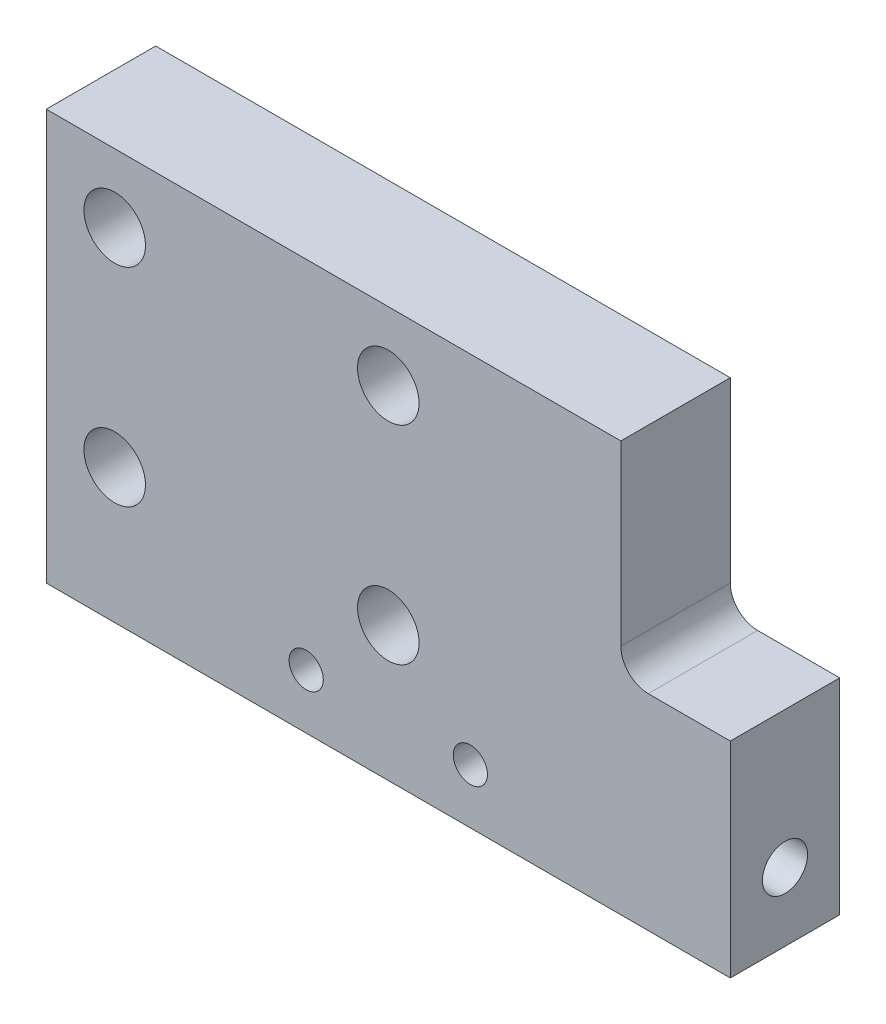
from build123d import *

# Parameters (mm, degrees)
SKETCH2_R             = 2.25
BOSS_EXTRUDE1_DEPTH   = 8
M3_TAPPED_HOLE1_D     = 2.5
M3_TAPPED_HOLE1_DEPTH = 7.5
M3_TAPPED_HOLE1_TIP   = 0.751075774
M4_TAPPED_HOLE1_D     = 3.3
M4_TAPPED_HOLE1_DEPTH = 8
M4_TAPPED_HOLE1_TIP   = 0.991420021
M4_TAPPED_HOLE2_D     = 3.3
M4_TAPPED_HOLE2_DEPTH = 8
M4_TAPPED_HOLE2_TIP   = 0.991420021
FILLET1_R             = 2


with BuildPart() as part:
    # Sketch2 → Boss-Extrude1 (new body)
    with BuildSketch(Plane.XY):
        Polygon((-21.629213483, 13.033707865), (20.370786517, 13.033707865), (20.370786517, -1.966292135), (28.370786517, -1.966292135), (28.370786517, -16.966292135), (-21.629213483, -16.966292135), align=None)
        with Locations((-16.629213483, 8.033707865)):
            Circle(SKETCH2_R, mode=Mode.SUBTRACT)
        with Locations((3.370786517, 8.033707865)):
            Circle(SKETCH2_R, mode=Mode.SUBTRACT)
        with Locations((-16.629213483, -7.134831461)):
            Circle(SKETCH2_R, mode=Mode.SUBTRACT)
        with Locations((3.370786517, -7.134831461)):
            Circle(SKETCH2_R, mode=Mode.SUBTRACT)
    extrude(amount=BOSS_EXTRUDE1_DEPTH)

    # M3 Tapped Hole1
    with Locations(Plane.XY.offset(8)):
        with Locations((-2.629213483, -12.966292135), (9.370786517, -12.966292135)):
            Hole(M3_TAPPED_HOLE1_D / 2, depth=M3_TAPPED_HOLE1_DEPTH)
            with Locations((0, 0, -(M3_TAPPED_HOLE1_DEPTH + M3_TAPPED_HOLE1_TIP / 2))):  # 118° drill point
                Cone(0, M3_TAPPED_HOLE1_D / 2, M3_TAPPED_HOLE1_TIP, mode=Mode.SUBTRACT)

    # M4 Tapped Hole1
    with Locations(Plane(origin=(28.370786517, 0, 0), x_dir=(0, 0, -1), z_dir=(1, 0, 0))):
        with Locations((-4, -11.966292135)):
            Hole(M4_TAPPED_HOLE1_D / 2, depth=M4_TAPPED_HOLE1_DEPTH)
            with Locations((0, 0, -(M4_TAPPED_HOLE1_DEPTH + M4_TAPPED_HOLE1_TIP / 2))):  # 118° drill point
                Cone(0, M4_TAPPED_HOLE1_D / 2, M4_TAPPED_HOLE1_TIP, mode=Mode.SUBTRACT)

    # M4 Tapped Hole2
    with Locations(Plane.ZY.offset(21.629213483)):
        with Locations((4, -11.966292135)):
            Hole(M4_TAPPED_HOLE2_D / 2, depth=M4_TAPPED_HOLE2_DEPTH)
            with Locations((0, 0, -(M4_TAPPED_HOLE2_DEPTH + M4_TAPPED_HOLE2_TIP / 2))):  # 118° drill point
                Cone(0, M4_TAPPED_HOLE2_D / 2, M4_TAPPED_HOLE2_TIP, mode=Mode.SUBTRACT)

    # Fillet1
    fillet1_edges = [part.edges().sort_by_distance(p)[0] for p in [
        (20.370786517, -1.966292135, 4),
    ]]
    fillet(fillet1_edges, radius=FILLET1_R)


solid = part.part
